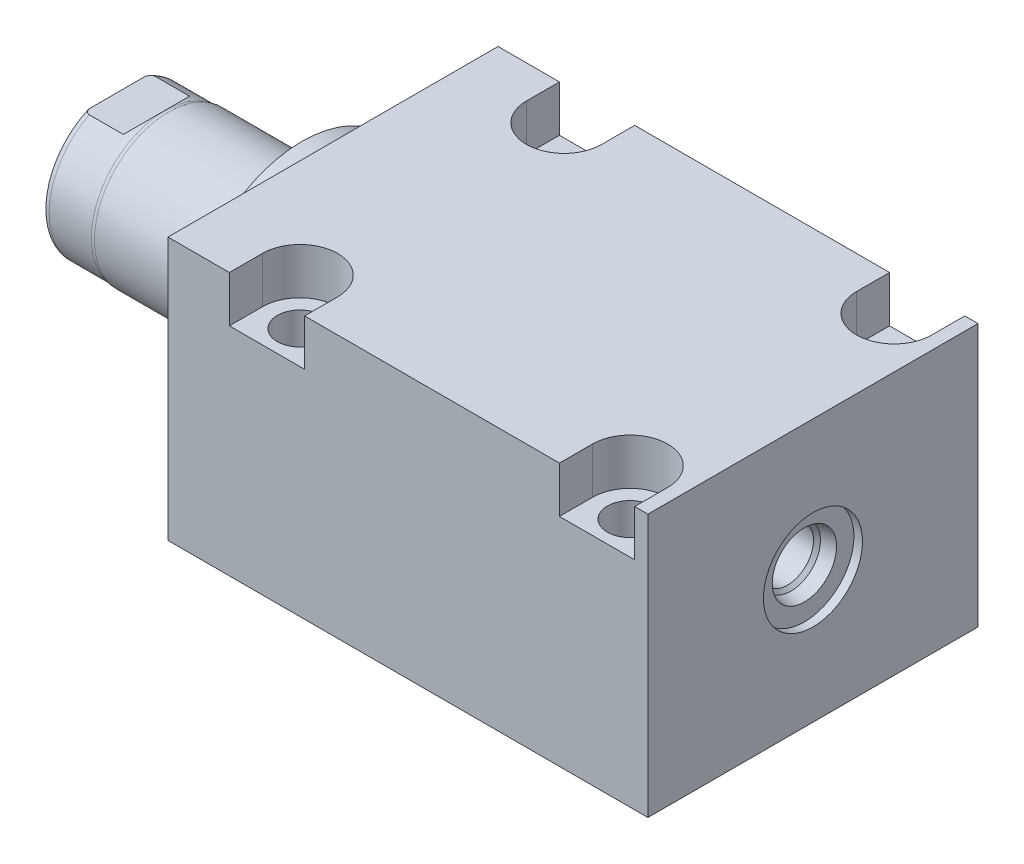
from build123d import *

# Parameters (mm, degrees)
SKETCH1_W          = 63.5
SKETCH1_H          = 50.546
EXTRUDE1_DEPTH     = 92.329
SKETCH5_R          = 22.225
EXTRUDE2_DEPTH     = 5.969
SKETCH6_W          = 14.2875
SKETCH6_H          = 35.56
CUT_EXTRUDE4_DEPTH = 30.48
HOLE2_D            = 8.7376
HOLE2_DEPTH        = 50.546
LPATTERN1_COUNT    = 2
LPATTERN1_PITCH    = 63.5
CUT_EXTRUDE5_DEPTH = 8.89
HOLE3_D            = 3.175
HOLE3_DEPTH        = 9.525
HOLE3_CBORE_D      = 11.3411
HOLE3_CBORE_DEPTH  = 1.4478
HOLE3_TIP          = 0.953866233
HOLE4_D            = 3.175
HOLE4_DEPTH        = 9.525
HOLE4_CBORE_D      = 11.3411
HOLE4_CBORE_DEPTH  = 1.4478
HOLE4_TIP          = 0.953866233
CHAMFER1_SIZE      = 0.635
SKETCH23_R         = 1.4478
LPATTERN3_COUNT    = 2
LPATTERN3_PITCH    = 63.5


with BuildPart() as part:
    # Sketch1 → Extrude1 (new body)
    with BuildSketch(Plane(origin=(0, 0, 0), x_dir=(0, 0, -1), z_dir=(1, 0, 0))):
        with Locations((0, -0.127)):
            Rectangle(SKETCH1_W, SKETCH1_H)
    extrude(amount=EXTRUDE1_DEPTH)

    # Sketch5 → Extrude2 (add)
    with BuildSketch(Plane.ZY):
        with Locations(Location((0, 0, 0), (0, 0, 180))):  # turned: the seam where the file's is
            Circle(SKETCH5_R)
    extrude(amount=EXTRUDE2_DEPTH)

    # Sketch6 → Revolve1 (revolve)
    with BuildSketch(Plane(origin=(0, 0, 0), x_dir=(0, 0, 1), z_dir=(0, -1, 0))):
        with Locations((-7.14375, 23.749)):
            Rectangle(SKETCH6_W, SKETCH6_H)
    revolve(axis=Axis((5.754582971, 0, 0), (-1, 0, 0)))

    # S2D0001 → Cut-Revolve4 (revolve, cut)
    with BuildSketch(Plane(origin=(-18.511260017, 3.2639, 0), x_dir=(0, 1, 0), z_dir=(0, 0, 1)), mode=Mode.PRIVATE) as cut_revolve4_sk:
        Polygon((2.286, 20.950017728), (2.286, 6.634739983), (-3.2639, 6.634739983), (-3.2639, 23.017739983), (3.4798, 23.017739983), align=None)
    revolve(cut_revolve4_sk.sketch.rotate(Axis((0, 0, 0), (-1, 0, 0)), 90), axis=Axis((0, 0, 0), (-1, 0, 0)), mode=Mode.SUBTRACT)  # turned: the seam where the file's is

    # Sketch8 → Cut-Revolve5 (revolve, cut)
    with BuildSketch(Plane(origin=(0, 0, 0), x_dir=(0, 0, -1), z_dir=(0, 1, 0)), mode=Mode.PRIVATE) as cut_revolve5_sk:
        with BuildLine():
            Line((-14.2875, 31.623), (-14.097, 32.385))
            Line((-14.097, 32.385), (-14.097, 40.513))
            ThreePointArc((-14.097, 40.513), (-13.996678675, 41.056796865), (-13.708922533, 41.529))
            Line((-13.708922533, 41.529), (-14.2875, 41.529))
            Line((-14.2875, 41.529), (-14.2875, 31.623))
        make_face()
    revolve(cut_revolve5_sk.sketch.rotate(Axis((-12.65936, 0, 0), (-1, 0, 0)), 180), axis=Axis((-12.65936, 0, 0), (-1, 0, 0)), mode=Mode.SUBTRACT)  # turned: the seam where the file's is

    # Sketch12 → Cut-Extrude4 (cut, symmetric)
    with BuildSketch(Plane(origin=(0, 0, 0), x_dir=(0, -1, 0), z_dir=(0, 0, -1))):
        Polygon((12.573, 41.529), (12.573, 33.9598), (14.097, 32.4358), (14.097, 41.529), align=None)
        Polygon((-12.573, 41.529), (-12.573, 33.9598), (-14.097, 32.4358), (-14.097, 41.529), align=None)
    extrude(amount=CUT_EXTRUDE4_DEPTH, both=True, mode=Mode.SUBTRACT)

    # Hole2
    with Locations(Plane(origin=(0, 25.146, 0), x_dir=(-1, 0, 0), z_dir=(0, 1, 0))):
        with Locations((-19.05, -25.4), (-19.05, 25.4)):
            hole2 = Hole(HOLE2_D / 2, depth=HOLE2_DEPTH)

    # LPattern1: Hole2 ×2
    with Locations(*[(i * LPATTERN1_PITCH, 0, 0) for i in range(1, LPATTERN1_COUNT)]):
        add(hole2, mode=Mode.SUBTRACT)

    # Sketch18 → Cut-Extrude5 (cut)
    with BuildSketch(Plane(origin=(0, 25.146, 0), x_dir=(1, 0, 0), z_dir=(0, 1, 0))):
        with BuildLine():
            Line((89.789, -31.75), (75.311, -31.75))
            Line((75.311, -31.75), (75.311, -25.4))
            ThreePointArc((75.311, -25.4), (82.55, -18.161), (89.789, -25.4))
            Line((89.789, -25.4), (89.789, -31.75))
        make_face()
        with BuildLine():
            Line((11.811, -25.4), (11.811, -31.75))
            Line((11.811, -31.75), (26.289, -31.75))
            Line((26.289, -31.75), (26.289, -25.4))
            ThreePointArc((26.289, -25.4), (19.05, -18.161), (11.811, -25.4))
        make_face()
        with BuildLine():
            Line((89.789, 25.4), (89.789, 31.75))
            Line((89.789, 31.75), (75.311, 31.75))
            Line((75.311, 31.75), (75.311, 25.4))
            ThreePointArc((75.311, 25.4), (82.55, 18.161), (89.789, 25.4))
        make_face()
        with BuildLine():
            Line((26.289, 31.75), (11.811, 31.75))
            Line((11.811, 31.75), (11.811, 25.4))
            ThreePointArc((11.811, 25.4), (19.05, 18.161), (26.289, 25.4))
            Line((26.289, 25.4), (26.289, 31.75))
        make_face()
    extrude(amount=-CUT_EXTRUDE5_DEPTH, mode=Mode.SUBTRACT)

    # Hole3
    with Locations(Plane.XZ.offset(25.4)):
        with Locations((12.7, 0)):
            CounterBoreHole(HOLE3_D / 2, HOLE3_CBORE_D / 2, HOLE3_CBORE_DEPTH, depth=HOLE3_DEPTH)
            with Locations((0, 0, -(HOLE3_DEPTH + HOLE3_TIP / 2))):  # 118° drill point
                Cone(0, HOLE3_D / 2, HOLE3_TIP, mode=Mode.SUBTRACT)

    # Hole4
    with Locations(Plane.XZ.offset(25.4)):
        with Locations((76.2, 0)):
            CounterBoreHole(HOLE4_D / 2, HOLE4_CBORE_D / 2, HOLE4_CBORE_DEPTH, depth=HOLE4_DEPTH)
            with Locations((0, 0, -(HOLE4_DEPTH + HOLE4_TIP / 2))):  # 118° drill point
                Cone(0, HOLE4_D / 2, HOLE4_TIP, mode=Mode.SUBTRACT)

    # Chamfer1
    chamfer1_edges = [part.edges().sort_by_distance(p)[0] for p in [
        (14.2875, -23.9522, 0),
        (77.7875, -23.9522, 0),
    ]]
    chamfer(chamfer1_edges, length=CHAMFER1_SIZE)

    # Sketch24 → Cut-Revolve6 (revolve, cut)
    with BuildSketch(Plane.XY, mode=Mode.PRIVATE) as cut_revolve6_sk:
        Polygon((92.329, 9.525), (90.678, 9.525), (90.678, 6.1849), (88.1253, 5.642306865), (87.461393135, 4.9784), (76.073, 4.9784), (76.073, 0), (92.329, 0), align=None)
    revolve(cut_revolve6_sk.sketch.rotate(Axis((0, 0, 0), (1, 0, 0)), 270), axis=Axis((0, 0, 0), (1, 0, 0)), mode=Mode.SUBTRACT)  # turned: the seam where the file's is


with BuildPart() as body_2:
    # Sketch23 → Revolve2 (revolve)
    with BuildSketch(Plane.XY, mode=Mode.PRIVATE) as revolve2_sk:
        with Locations((8.47725, -25.4)):
            Circle(SKETCH23_R)
    revolve(revolve2_sk.sketch.rotate(Axis((12.7, -23.9522, 0), (0, 1, 0)), 270), axis=Axis((12.7, -23.9522, 0), (0, 1, 0)))  # turned: the seam where the file's is


with BuildPart() as lpattern3_1:
    # LPattern3: pattern copy
    add(body_2.part.moved(Location(Vector(1, 0, 0) * (1 * LPATTERN3_PITCH))))


solid = Compound([part.part, body_2.part, lpattern3_1.part])
